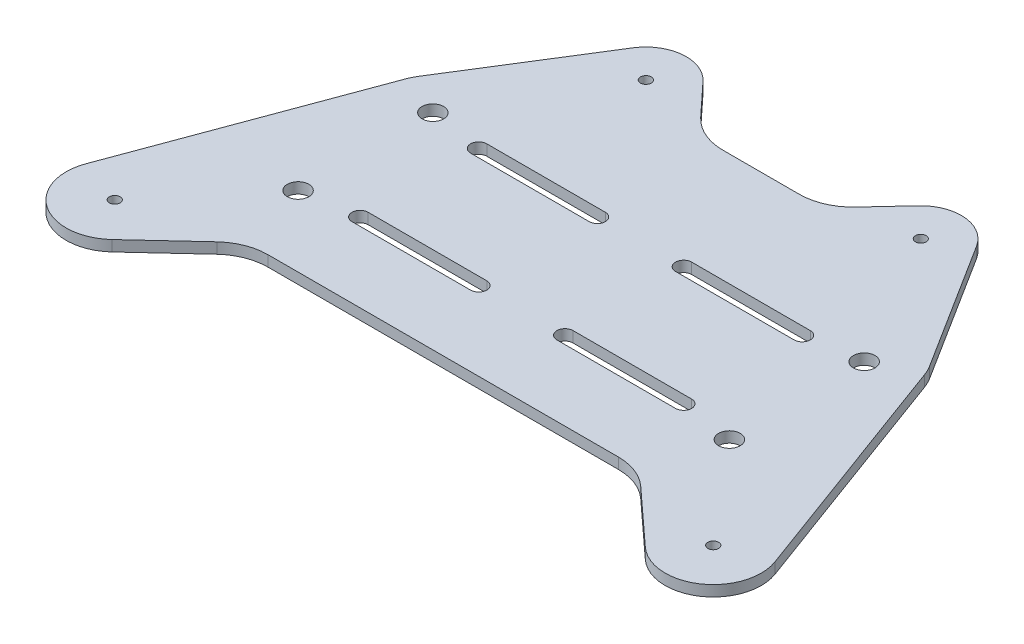
from build123d import *

# Parameters (mm, degrees)
SKETCH1_W           = 130
SKETCH1_H           = 90
BOSS_EXTRUDE2_DEPTH = 2
SKETCH2_R           = 2
CUT_EXTRUDE1_DEPTH  = 10
CUT_EXTRUDE3_DEPTH  = 10
SKETCH5_R           = 1
CUT_EXTRUDE4_DEPTH  = 10
CUT_EXTRUDE5_DEPTH  = 3
FILLET1_R           = 10


with BuildPart() as part:
    # Sketch1 → Boss-Extrude2 (new body)
    with BuildSketch(Plane(origin=(0, 0, 0), x_dir=(1, 0, 0), z_dir=(0, 1, 0))):
        with Locations((56.787418592, 40.403463793)):
            Rectangle(SKETCH1_W, SKETCH1_H)
    extrude(amount=BOSS_EXTRUDE2_DEPTH)

    # Sketch2 → Cut-Extrude1 (cut)
    with BuildSketch(Plane(origin=(0, 2, 0), x_dir=(1, 0, 0), z_dir=(0, 1, 0))):
        with Locations((16.787418592, 52.903463793)):
            Circle(SKETCH2_R)
        with Locations((16.787418592, 27.903463793)):
            Circle(SKETCH2_R)
        with Locations((96.787418592, 52.903463793)):
            Circle(SKETCH2_R)
        with Locations((96.787418592, 27.903463793)):
            Circle(SKETCH2_R)
    extrude(amount=-CUT_EXTRUDE1_DEPTH, mode=Mode.SUBTRACT)

    # Sketch4 → Cut-Extrude3 (cut)
    with BuildSketch(Plane(origin=(0, 2, 0), x_dir=(1, 0, 0), z_dir=(0, 1, 0))):
        with BuildLine():
            Line((26.787418592, 52.903463793), (48.787418592, 52.903463793))
            ThreePointArc((48.787418592, 52.903463793), (50.287418592, 51.403463793), (48.787418592, 49.903463793))
            Line((48.787418592, 49.903463793), (26.787418592, 49.903463793))
            ThreePointArc((26.787418592, 49.903463793), (25.287418592, 51.403463793), (26.787418592, 52.903463793))
        make_face()
        with BuildLine():
            Line((26.787418592, 30.903463793), (48.787418592, 30.903463793))
            ThreePointArc((48.787418592, 30.903463793), (50.287418592, 29.403463793), (48.787418592, 27.903463793))
            Line((48.787418592, 27.903463793), (26.787418592, 27.903463793))
            ThreePointArc((26.787418592, 27.903463793), (25.287418592, 29.403463793), (26.787418592, 30.903463793))
        make_face()
        with BuildLine():
            Line((64.787418592, 52.903463793), (86.787418592, 52.903463793))
            ThreePointArc((86.787418592, 52.903463793), (88.287418592, 51.403463793), (86.787418592, 49.903463793))
            Line((86.787418592, 49.903463793), (64.787418592, 49.903463793))
            ThreePointArc((64.787418592, 49.903463793), (63.287418592, 51.403463793), (64.787418592, 52.903463793))
        make_face()
        with BuildLine():
            Line((64.787418592, 30.903463793), (86.787418592, 30.903463793))
            ThreePointArc((86.787418592, 30.903463793), (88.287418592, 29.403463793), (86.787418592, 27.903463793))
            Line((86.787418592, 27.903463793), (64.787418592, 27.903463793))
            ThreePointArc((64.787418592, 27.903463793), (63.287418592, 29.403463793), (64.787418592, 30.903463793))
        make_face()
    extrude(amount=-CUT_EXTRUDE3_DEPTH, mode=Mode.SUBTRACT)

    # Sketch5 → Cut-Extrude4 (cut)
    with BuildSketch(Plane(origin=(0, 2, 0), x_dir=(1, 0, 0), z_dir=(0, 1, 0))):
        with Locations((1.287418592, 9.403463793)):
            Circle(SKETCH5_R)
        with Locations((112.287418592, 9.403463793)):
            Circle(SKETCH5_R)
        with Locations((31.287418592, 77.903463793)):
            Circle(SKETCH5_R)
        with Locations((82.287418592, 77.903463793)):
            Circle(SKETCH5_R)
    extrude(amount=-CUT_EXTRUDE4_DEPTH, mode=Mode.SUBTRACT)

    # Sketch6 → Cut-Extrude5 (cut, through all)
    with BuildSketch(Plane(origin=(0, 2, 0), x_dir=(1, 0, 0), z_dir=(0, 1, 0))):
        with BuildLine():
            Line((31.287418742, 85.403463793), (-8.212581408, 85.403463793))
            Line((-8.212581408, 85.403463793), (-8.212581408, -4.596536207))
            Line((-8.212581408, -4.596536207), (121.787418592, -4.596536207))
            Line((121.787418592, -4.596536207), (121.787418592, 85.403463793))
            Line((121.787418592, 85.403463793), (82.287418592, 85.403463793))
            ThreePointArc((82.287418592, 85.403463793), (85.908182742, 84.471573641), (88.629172371, 81.907481652))
            Line((88.629172371, 81.907481652), (104.107184656, 57.392670192))
            Line((104.107184656, 57.392670192), (120.652052771, 12.485171021))
            ThreePointArc((120.652052771, 12.485171021), (117.254615926, 2.001371181), (106.265325845, 2.830913046))
            Line((106.265325845, 2.830913046), (93.195977552, 14.805689748))
            Line((93.195977552, 14.805689748), (20.378859632, 14.805689748))
            Line((20.378859632, 14.805689748), (7.425097101, 2.787815466))
            ThreePointArc((7.425097103, 2.787815464), (-3.723088928, 1.897951505), (-7.176040156, 12.53519915))
            Line((-7.176040154, 12.53519915), (8.848458195, 55.841119114))
            ThreePointArc((8.848458195, 55.841119114), (9.189915505, 56.63640604), (9.610794254, 57.392670192))
            Line((9.610794254, 57.392670192), (24.928951385, 81.880886929))
            ThreePointArc((24.928951386, 81.880886928), (27.652908616, 84.463977282), (31.287418742, 85.403463793))
        make_face()
        with BuildLine():
            Line((82.287418592, 85.403463793), (31.287418742, 85.403463793))
            ThreePointArc((31.287418742, 85.403463793), (34.283566796, 84.779007113), (36.780790962, 83.00962282))
            Line((36.780790963, 83.009622821), (45.361476392, 73.77824166))
            Line((45.361476392, 73.77824166), (68.213360792, 73.77824166))
            Line((68.213360792, 73.77824166), (76.794046223, 83.009622821))
            ThreePointArc((76.794046223, 83.009622821), (79.291270457, 84.779007143), (82.287418592, 85.403463793))
        make_face()
    extrude(amount=-CUT_EXTRUDE5_DEPTH, mode=Mode.SUBTRACT)

    # Fillet1
    fillet1_edges = [part.edges().sort_by_distance(p)[0] for p in [
        (68.213360792, 1, -73.77824166),
        (45.361476392, 1, -73.77824166),
        (20.378859632, 1, -14.805689748),
        (93.195977552, 1, -14.805689748),
        (104.107184656, 1, -57.392670192),
    ]]
    fillet(fillet1_edges, radius=FILLET1_R)


solid = part.part
